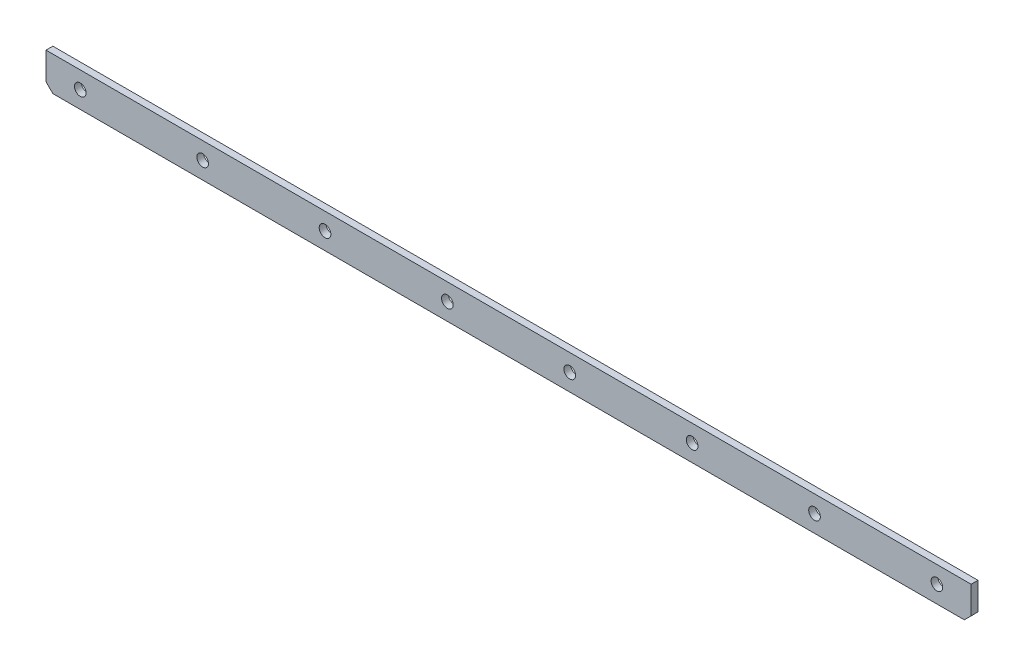
from build123d import *

# Parameters (mm, degrees)
SKETCH1_W            = 270
SKETCH1_H            = 10
BOSS_EXTRUDE1_DEPTH  = 2
CHAMFER1_SIZE        = 2
M3_CLEARANCE_HOLE1_D = 3.4
LPATTERN1_COUNT      = 8
LPATTERN1_PITCH      = 35.714285714


with BuildPart() as part:
    # Sketch1 → Boss-Extrude1 (new body)
    with BuildSketch(Plane.XY):
        Rectangle(SKETCH1_W, SKETCH1_H)
    extrude(amount=BOSS_EXTRUDE1_DEPTH)

    # Chamfer1
    chamfer1_edges = [part.edges().sort_by_distance(p)[0] for p in [
        (135, -5, 1),
        (-135, -5, 1),
    ]]
    chamfer(chamfer1_edges, length=CHAMFER1_SIZE)

    # M3 Clearance Hole1 (through all)
    with Locations(Plane.XY.offset(2)):
        with Locations((125, 0)):
            m3_clearance_hole1 = Hole(M3_CLEARANCE_HOLE1_D / 2)

    # LPattern1: M3 Clearance Hole1 ×8
    with Locations(*[(-i * LPATTERN1_PITCH, 0, 0) for i in range(1, LPATTERN1_COUNT)]):
        add(m3_clearance_hole1, mode=Mode.SUBTRACT)


solid = part.part
